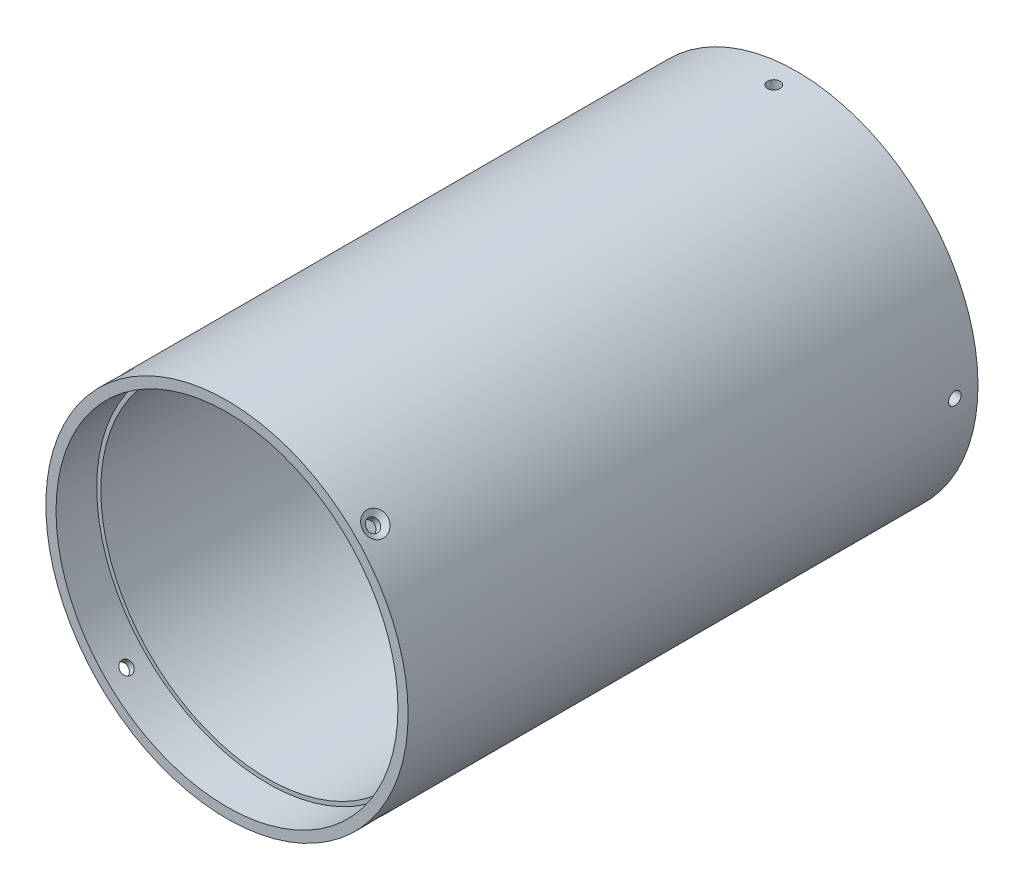
from build123d import *

# Parameters (mm, degrees)
ESQUISSE1_R                  = 44.5
BOSS_EXTRU_1_DEPTH           = 140
ESQUISSE2_R                  = 42
ENL_V_MAT_EXTRU_1_DEPTH      = 150
R_P_TITION_CIRCULAIRE1_COUNT = 4
ESQUISSE8_W                  = 1
ESQUISSE8_H                  = 130
R_P_TITION_CIRCULAIRE2_COUNT = 4


with BuildPart() as part:
    # Esquisse1 → Boss.-Extru.1 (new body)
    with BuildSketch(Plane.XY):
        Circle(ESQUISSE1_R)
    extrude(amount=BOSS_EXTRU_1_DEPTH)

    # Esquisse2 → Enlèv. mat.-Extru.1 (cut)
    with BuildSketch(Plane(origin=(0, 0, 0), x_dir=(-1, 0, 0), z_dir=(0, 0, -1))):
        Circle(ESQUISSE2_R)
    extrude(amount=-ENL_V_MAT_EXTRU_1_DEPTH, mode=Mode.SUBTRACT)

    # Esquisse5 → Dégagement M2.51 (revolve, cut)
    with BuildSketch(Plane(origin=(-31.466251763, 31.466251763, 135), x_dir=(-0.707106781, -0.707106781, 0), z_dir=(0, 0, 1))):
        Polygon((0, 0), (0, 15.931333959), (1.55, 15), (1.55, 0.83715789), (3, 0), align=None)
    d_gagement_m2_51 = revolve(axis=Axis((-35.956379823, 35.956379823, 135), (0.707106781, -0.707106781, 0)), mode=Mode.SUBTRACT)

    # Répétition circulaire1: Dégagement M2.51 ×4 about axis
    r_p_tition_circulaire1_axis = Axis((0, 0, 150), (0, 0, -1))
    for i in range(1, R_P_TITION_CIRCULAIRE1_COUNT):
        add(d_gagement_m2_51.rotate(r_p_tition_circulaire1_axis, i * 360 / R_P_TITION_CIRCULAIRE1_COUNT), mode=Mode.SUBTRACT)

    # Esquisse8 → Révolution1 (revolve)
    with BuildSketch(Plane(origin=(0, 0, 0), x_dir=(1, 0, 0), z_dir=(0, 1, 0))):
        with Locations((-41.5, -65)):
            Rectangle(ESQUISSE8_W, ESQUISSE8_H)
    revolve(axis=Axis((0, 0, -17.420915561), (0, 0, 1)))

    # Esquisse7 → Dégagement M2.52 (revolve, cut)
    with BuildSketch(Plane(origin=(-44.5, 0, 5.7), x_dir=(0, 0, 1), z_dir=(0, 1, 0))):
        Polygon((0, 0), (0, 20.931333959), (1.55, 20), (1.55, 0), align=None)
    d_gagement_m2_52 = revolve(axis=Axis((-50.85, 0, 5.7), (1, 0, 0)), mode=Mode.SUBTRACT)

    # Répétition circulaire2: Dégagement M2.52 ×4 about axis
    r_p_tition_circulaire2_axis = Axis((0, 0, 0), (0, 0, 1))
    for i in range(1, R_P_TITION_CIRCULAIRE2_COUNT):
        add(d_gagement_m2_52.rotate(r_p_tition_circulaire2_axis, i * 360 / R_P_TITION_CIRCULAIRE2_COUNT), mode=Mode.SUBTRACT)


solid = part.part
